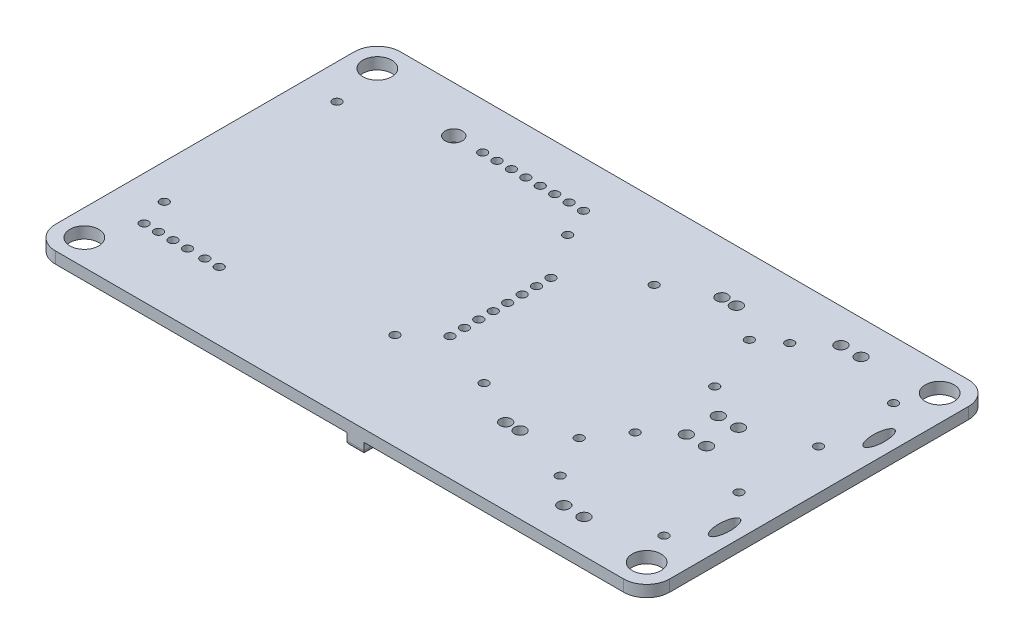
from build123d import *

# Parameters (mm, degrees)
SKETCH1_W           = 213
SKETCH1_H           = 119.6
SKETCH1_R           = 1.5
SKETCH1_R_2         = 1.499999994
SKETCH1_R_3         = 2
SKETCH1_R_4         = 2.000000002
SKETCH1_R_5         = 5
BOSS_EXTRUDE1_DEPTH = 4
SKETCH5_R           = 1.5
SKETCH5_R_2         = 2
SKETCH5_RX          = 5.303428227
SKETCH5_RY          = 2
CUT_EXTRUDE1_DEPTH  = 4
SKETCH6_R           = 3
CUT_EXTRUDE2_DEPTH  = 4
SKETCH7_W           = 109
SKETCH7_H           = 3.522810192
SKETCH7_W_2         = 6
SKETCH7_H_2         = 119.6
SKETCH7_W_3         = 82.957650312
BOSS_EXTRUDE2_DEPTH = 4
FILLET7_R           = 1.5
FILLET8_R           = 8
FILLET9_R           = 8
FILLET10_R          = 8
FILLET11_R          = 8


with BuildPart() as part:
    # Sketch1 → Boss-Extrude1 (new body)
    with BuildSketch(Plane(origin=(0, 0, 0), x_dir=(1, 0, 0), z_dir=(0, 1, 0))):
        with Locations((106.5, 59.8)):
            Rectangle(SKETCH1_W, SKETCH1_H)
        with Locations((12, 93.6)):
            Circle(SKETCH1_R, mode=Mode.SUBTRACT)
        with Locations((12.113582234, 33.600107508)):
            Circle(SKETCH1_R, mode=Mode.SUBTRACT)
        with Locations((92, 93.6)):
            Circle(SKETCH1_R_2, mode=Mode.SUBTRACT)
        with Locations((92.113582234, 33.600107508)):
            Circle(SKETCH1_R, mode=Mode.SUBTRACT)
        with Locations((87.5, 103.6)):
            Circle(SKETCH1_R_2, mode=Mode.SUBTRACT)
        with Locations((102, 77.8)):
            Circle(SKETCH1_R_2, mode=Mode.SUBTRACT)
        with Locations((82.5, 103.6)):
            Circle(SKETCH1_R_2, mode=Mode.SUBTRACT)
        with Locations((77.5, 103.6)):
            Circle(SKETCH1_R_2, mode=Mode.SUBTRACT)
        with Locations((72.5, 103.6)):
            Circle(SKETCH1_R_2, mode=Mode.SUBTRACT)
        with Locations((67.5, 103.6)):
            Circle(SKETCH1_R_2, mode=Mode.SUBTRACT)
        with Locations((62.5, 103.6)):
            Circle(SKETCH1_R_2, mode=Mode.SUBTRACT)
        with Locations((57.5, 103.6)):
            Circle(SKETCH1_R_2, mode=Mode.SUBTRACT)
        with Locations((52.5, 103.6)):
            Circle(SKETCH1_R_2, mode=Mode.SUBTRACT)
        with Locations((102, 72.8)):
            Circle(SKETCH1_R_2, mode=Mode.SUBTRACT)
        with Locations((102, 67.8)):
            Circle(SKETCH1_R_2, mode=Mode.SUBTRACT)
        with Locations((102, 62.8)):
            Circle(SKETCH1_R_2, mode=Mode.SUBTRACT)
        with Locations((102, 57.8)):
            Circle(SKETCH1_R_2, mode=Mode.SUBTRACT)
        with Locations((102, 52.8)):
            Circle(SKETCH1_R_2, mode=Mode.SUBTRACT)
        with Locations((102, 47.8)):
            Circle(SKETCH1_R_2, mode=Mode.SUBTRACT)
        with Locations((102, 42.8)):
            Circle(SKETCH1_R_2, mode=Mode.SUBTRACT)
        with Locations((122, 93.6)):
            Circle(SKETCH1_R, mode=Mode.SUBTRACT)
        with Locations((155, 93.6)):
            Circle(SKETCH1_R, mode=Mode.SUBTRACT)
        with Locations((122, 34.6)):
            Circle(SKETCH1_R, mode=Mode.SUBTRACT)
        with Locations((155, 34.6)):
            Circle(SKETCH1_R, mode=Mode.SUBTRACT)
        with Locations((15.113582234, 23.600107508)):
            Circle(SKETCH1_R, mode=Mode.SUBTRACT)
        with Locations((20.137829951, 23.600107508)):
            Circle(SKETCH1_R, mode=Mode.SUBTRACT)
        with Locations((25.162077668, 23.600107508)):
            Circle(SKETCH1_R, mode=Mode.SUBTRACT)
        with Locations((30.186325385, 23.600107508)):
            Circle(SKETCH1_R, mode=Mode.SUBTRACT)
        with Locations((36.186325385, 23.600107508)):
            Circle(SKETCH1_R, mode=Mode.SUBTRACT)
        with Locations((41.186325385, 23.600107508)):
            Circle(SKETCH1_R, mode=Mode.SUBTRACT)
        with Locations((137.5, 101.6)):
            Circle(SKETCH1_R_3, mode=Mode.SUBTRACT)
        with Locations((142.5, 101.6)):
            Circle(SKETCH1_R_4, mode=Mode.SUBTRACT)
        with Locations((137.5, 26.6)):
            Circle(SKETCH1_R_3, mode=Mode.SUBTRACT)
        with Locations((142.5, 26.6)):
            Circle(SKETCH1_R_3, mode=Mode.SUBTRACT)
        with Locations((9, 110.6)):
            Circle(SKETCH1_R_5, mode=Mode.SUBTRACT)
        with Locations((9, 9)):
            Circle(SKETCH1_R_5, mode=Mode.SUBTRACT)
        with Locations((204, 110.6)):
            Circle(SKETCH1_R_5, mode=Mode.SUBTRACT)
        with Locations((204, 9)):
            Circle(SKETCH1_R_5, mode=Mode.SUBTRACT)
    extrude(amount=BOSS_EXTRUDE1_DEPTH)

    # Sketch5 → Cut-Extrude1 (cut)
    with BuildSketch(Plane(origin=(0, 4, 0), x_dir=(1, 0, 0), z_dir=(0, 1, 0))):
        with Locations((199.004449887, 99.6)):
            Circle(SKETCH5_R)
        with Locations((199.006879067, 73.600000113)):
            Circle(SKETCH5_R)
        with Locations((163.004450044, 99.596636519)):
            Circle(SKETCH5_R)
        with Locations((163.006879224, 73.596636633)):
            Circle(SKETCH5_R)
        with Locations((172.5, 107.84619775)):
            Circle(SKETCH5_R_2)
        with Locations((179.5, 107.84619775)):
            Circle(SKETCH5_R_2)
        with Locations((172.506879224, 65.346636633)):
            Circle(SKETCH5_R_2)
        with Locations((179.506879224, 65.346636633)):
            Circle(SKETCH5_R_2)
        with Locations((199.011329111, 45.999999887)):
            Circle(SKETCH5_R)
        with Locations((199.013758291, 20)):
            Circle(SKETCH5_R)
        with Locations((163.011329268, 45.996636406)):
            Circle(SKETCH5_R)
        with Locations((163.013758448, 19.996636519)):
            Circle(SKETCH5_R)
        with Locations((172.506879224, 54.246197637)):
            Circle(SKETCH5_R_2)
        with Locations((179.506879224, 54.246197637)):
            Circle(SKETCH5_R_2)
        with Locations((172.513758448, 11.746636519)):
            Circle(SKETCH5_R_2)
        with Locations((179.513758448, 11.746636519)):
            Circle(SKETCH5_R_2)
        with Locations(Location((207.004450044, 86.596636519), (0, 0, -90))):
            Ellipse(SKETCH5_RX, SKETCH5_RY)
        with Locations(Location((207.011329268, 32.996636406), (0, 0, -90))):
            Ellipse(SKETCH5_RX, SKETCH5_RY)
    extrude(amount=-CUT_EXTRUDE1_DEPTH, mode=Mode.SUBTRACT)

    # Sketch6 → Cut-Extrude2 (cut)
    with BuildSketch(Plane(origin=(0, 4, 0), x_dir=(1, 0, 0), z_dir=(0, 1, 0))):
        with Locations((42.5, 103.6)):
            Circle(SKETCH6_R)
    extrude(amount=-CUT_EXTRUDE2_DEPTH, mode=Mode.SUBTRACT)

    # Sketch7 → Boss-Extrude2 (add)
    with BuildSketch(Plane.XZ):
        with Locations((54.5, -84.838594904)):
            Rectangle(SKETCH7_W, SKETCH7_H)
        with Locations((112, -59.8)):
            Rectangle(SKETCH7_W_2, SKETCH7_H_2)
        with Locations((156.478825156, -84.838594904)):
            Rectangle(SKETCH7_W_3, SKETCH7_H)
    extrude(amount=BOSS_EXTRUDE2_DEPTH)

    # Fillet7
    fillet7_edges = [part.edges().sort_by_distance(p)[0] for p in [
        (0, -4, -84.838594904),
        (54.5, -4, -86.6),
        (115, -4, -103.1),
        (197.957650312, -4, -84.838594904),
        (156.478825156, -4, -83.077189808),
        (115, -4, -41.538594904),
        (112, -4, 0),
        (109, -4, -103.1),
        (112, -4, -119.6),
        (156.478825156, -4, -86.6),
        (109, -4, -41.538594904),
        (54.5, -4, -83.077189808),
    ]]
    fillet(fillet7_edges, radius=FILLET7_R)

    # Fillet8
    fillet8_edges = [part.edges().sort_by_distance(p)[0] for p in [
        (0, 2, -119.6),
    ]]
    fillet(fillet8_edges, radius=FILLET8_R)

    # Fillet9
    fillet9_edges = [part.edges().sort_by_distance(p)[0] for p in [
        (213, 2, -119.6),
    ]]
    fillet(fillet9_edges, radius=FILLET9_R)

    # Fillet10
    fillet10_edges = [part.edges().sort_by_distance(p)[0] for p in [
        (213, 2, 0),
    ]]
    fillet(fillet10_edges, radius=FILLET10_R)

    # Fillet11
    fillet11_edges = [part.edges().sort_by_distance(p)[0] for p in [
        (0, 2, 0),
    ]]
    fillet(fillet11_edges, radius=FILLET11_R)


solid = part.part
